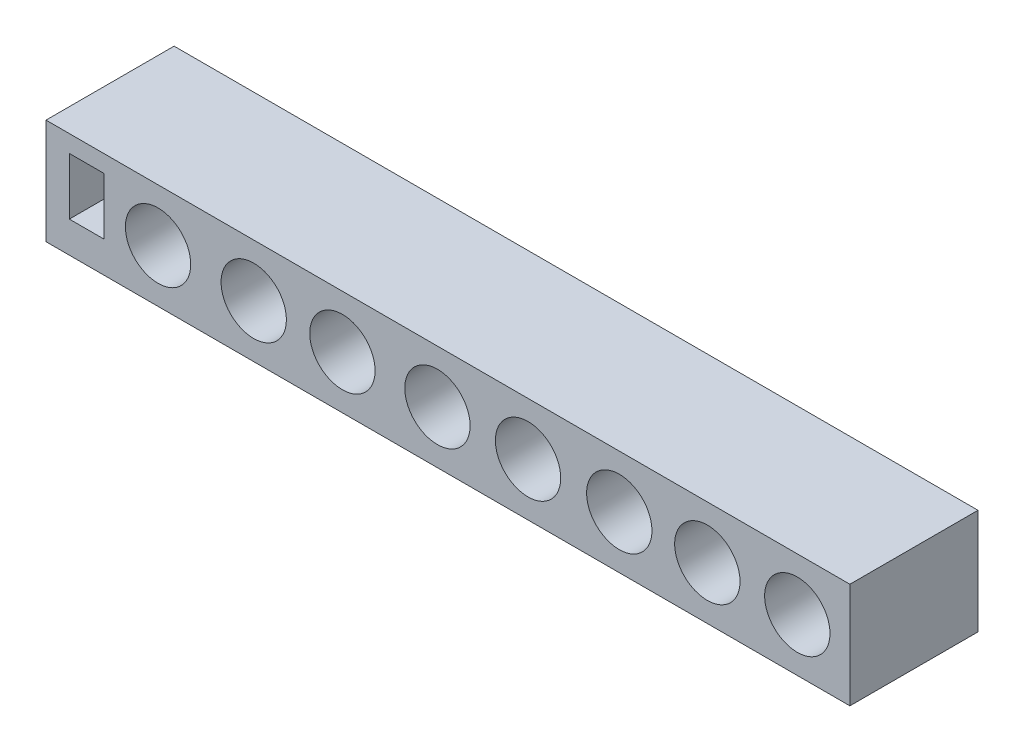
from build123d import *

# Parameters (mm, degrees)
SKETCH1_W           = 62.755543402
SKETCH1_H           = 8.222921835
BOSS_EXTRUDE1_DEPTH = 10
SKETCH1_3_R         = 2.55
SKETCH1_3_W         = 2.689412068
SKETCH1_3_H         = 4.439494762
CUT_EXTRUDE1_DEPTH  = 10
SKETCH1_4_R         = 2.8
SKETCH1_4_R_2       = 2.775
SKETCH1_4_R_3       = 2.75
SKETCH1_4_R_4       = 2.725
SKETCH1_4_R_5       = 2.825
SKETCH1_4_R_6       = 2.85
SKETCH1_4_R_7       = 2.875
SKETCH1_4_R_8       = 2.9
CUT_EXTRUDE2_DEPTH  = 1.2


with BuildPart() as part:
    # Sketch1 → Boss-Extrude1 (new body)
    with BuildSketch(Plane.XY):
        with Locations((31.377771701, 4.111460918)):
            Rectangle(SKETCH1_W, SKETCH1_H)
    extrude(amount=BOSS_EXTRUDE1_DEPTH)

    # Sketch1_3 → Cut-Extrude1 (cut)
    with BuildSketch(Plane.XY):
        with Locations((58.650458849, 4.111460918)):
            Circle(SKETCH1_3_R)
        with Locations((51.627302144, 4.111460918)):
            Circle(SKETCH1_3_R)
        with Locations((3.166946189, 4.661409139)):
            Rectangle(SKETCH1_3_W, SKETCH1_3_H)
        with Locations((44.752521989, 4.111460918)):
            Circle(SKETCH1_3_R)
        with Locations((8.746479161, 4.111460918)):
            Circle(SKETCH1_3_R)
        with Locations((37.630447583, 4.111460918)):
            Circle(SKETCH1_3_R)
        with Locations((16.214765516, 4.111460918)):
            Circle(SKETCH1_3_R)
        with Locations((30.557832028, 4.111460918)):
            Circle(SKETCH1_3_R)
        with Locations((23.139004522, 4.111460918)):
            Circle(SKETCH1_3_R)
    extrude(amount=CUT_EXTRUDE1_DEPTH, mode=Mode.SUBTRACT)

    # Sketch1_4 → Cut-Extrude2 (cut)
    with BuildSketch(Plane.XY):
        with Locations((8.746479161, 4.111460918)):
            Circle(SKETCH1_4_R)
        with Locations((16.214765516, 4.111460918)):
            Circle(SKETCH1_4_R_2)
        with Locations((23.139004522, 4.111460918)):
            Circle(SKETCH1_4_R_3)
        with Locations((30.557832028, 4.111460918)):
            Circle(SKETCH1_4_R_4)
        with Locations((37.630447583, 4.111460918)):
            Circle(SKETCH1_4_R_5)
        with Locations((44.752521989, 4.111460918)):
            Circle(SKETCH1_4_R_6)
        with Locations((51.627302144, 4.111460918)):
            Circle(SKETCH1_4_R_7)
        with Locations((58.650458849, 4.111460918)):
            Circle(SKETCH1_4_R_8)
    extrude(amount=CUT_EXTRUDE2_DEPTH, mode=Mode.SUBTRACT)


solid = part.part
